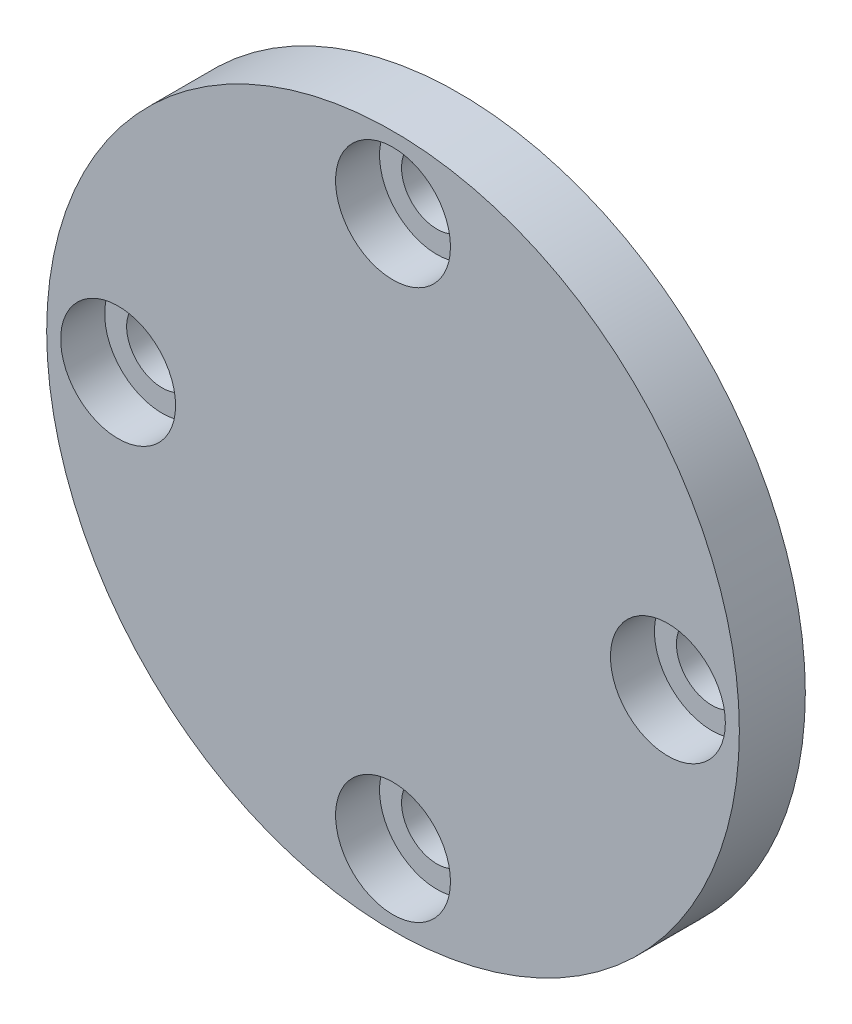
from build123d import *

# Parameters (mm, degrees)
SKETCH1_R              = 31.5
SKETCH1_R_2            = 3.225
MAIN_PA10_FLANGE_DEPTH = 6
SKETCH3_R              = 5.225
M6_HOLE_DEPTH          = 4


with BuildPart() as part:
    # Sketch1 → Main PA10 Flange (new body)
    with BuildSketch(Plane.XY):
        Circle(SKETCH1_R)
        with Locations((0, -25)):
            Circle(SKETCH1_R_2, mode=Mode.SUBTRACT)
        with Locations((-25, 0)):
            Circle(SKETCH1_R_2, mode=Mode.SUBTRACT)
        with Locations((0, 25)):
            Circle(SKETCH1_R_2, mode=Mode.SUBTRACT)
        with Locations((25, 0)):
            Circle(SKETCH1_R_2, mode=Mode.SUBTRACT)
    extrude(amount=MAIN_PA10_FLANGE_DEPTH)

    # Sketch3 → M6 Hole (cut)
    with BuildSketch(Plane.XY.offset(6)):
        with Locations((0, -25)):
            Circle(SKETCH3_R)
        with Locations((-25, 0)):
            Circle(SKETCH3_R)
        with Locations((0, 25)):
            Circle(SKETCH3_R)
        with Locations((25, 0)):
            Circle(SKETCH3_R)
    extrude(amount=-M6_HOLE_DEPTH, mode=Mode.SUBTRACT)


solid = part.part
